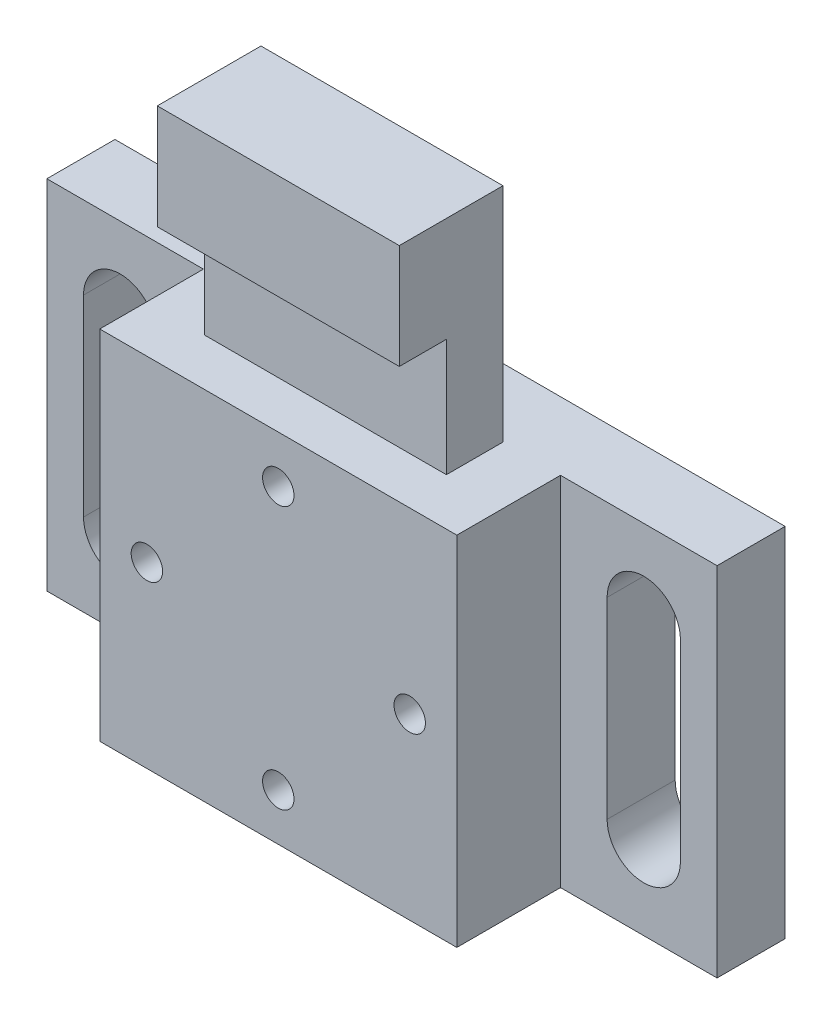
from build123d import *

# Parameters (mm, degrees)
SKETCH1_W           = 64
SKETCH1_H           = 34.1
BOSS_EXTRUDE1_DEPTH = 6.5
BOSS_EXTRUDE2_DEPTH = 9.9
SKETCH4_W           = 23.11
SKETCH4_H           = 11.2
CUT_EXTRUDE1_DEPTH  = 4.5
CUT_EXTRUDE2_DEPTH  = 7.5
SKETCH7_R           = 1.5
CUT_EXTRUDE3_DEPTH  = 10


with BuildPart() as part:
    # Sketch1 → Boss-Extrude1 (new body)
    with BuildSketch(Plane.XY):
        Rectangle(SKETCH1_W, SKETCH1_H)
    extrude(amount=BOSS_EXTRUDE1_DEPTH)

    # Sketch2 → Boss-Extrude2 (add)
    with BuildSketch(Plane.XY.offset(6.5)):
        Polygon((-17.05, 17.05), (-11.555, 17.05), (-11.555, 38.25), (11.555, 38.25), (11.555, 17.05), (17.05, 17.05), (17.05, -17.05), (-17.05, -17.05), align=None)
    extrude(amount=BOSS_EXTRUDE2_DEPTH)

    # Sketch4 → Cut-Extrude1 (cut)
    with BuildSketch(Plane.XY.offset(16.4)):
        with Locations((0, 22.65)):
            Rectangle(SKETCH4_W, SKETCH4_H)
    extrude(amount=-CUT_EXTRUDE1_DEPTH, mode=Mode.SUBTRACT)

    # Sketch6 → Cut-Extrude2 (cut, through all)
    with BuildSketch(Plane.XY.offset(6.5)):
        with BuildLine():
            Line((-21.5, 9.178681579), (-21.5, -9.178681579))
            ThreePointArc((-21.5, -9.178681579), (-25, -12.678681579), (-28.5, -9.178681579))
            Line((-28.5, -9.178681579), (-28.5, 9.178681579))
            ThreePointArc((-28.5, 9.178681579), (-25, 12.678681579), (-21.5, 9.178681579))
        make_face()
    cut_extrude2 = extrude(amount=-CUT_EXTRUDE2_DEPTH, mode=Mode.SUBTRACT)

    # Mirror1: Cut-Extrude2 across plane
    add(cut_extrude2.mirror(Plane(origin=(0, 0, 0), x_dir=(0, 0, 1), z_dir=(1, 0, 0))), mode=Mode.SUBTRACT)

    # Sketch7 → Cut-Extrude3 (cut)
    with BuildSketch(Plane.XY.offset(16.4)):
        with Locations((-12.55, 0)):
            Circle(SKETCH7_R)
        with Locations((12.55, 0)):
            Circle(SKETCH7_R)
        with Locations((0, 12.55)):
            Circle(SKETCH7_R)
        with Locations((0, -12.55)):
            Circle(SKETCH7_R)
    extrude(amount=-CUT_EXTRUDE3_DEPTH, mode=Mode.SUBTRACT)


solid = part.part
